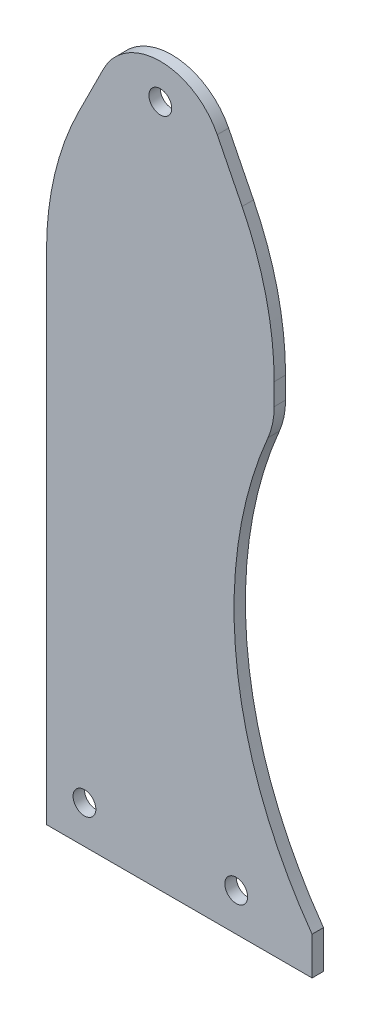
from build123d import *

# Parameters (mm, degrees)
SKETCH_1_R      = 3
EXTRUDE_1_DEPTH = 3


with BuildPart() as part:
    # 草图1 → 凸台-拉伸1 (new body)
    with BuildSketch(Plane.XY):
        with BuildLine():
            Line((8.44582472, 166.89164944), (15, 180))
            ThreePointArc((15, 180), (30, 189.270509831), (45, 180))
            Line((45, 180), (51.55417528, 166.89164944))
            ThreePointArc((51.55417528, 166.89164944), (57.859919157, 149.494795444), (60, 131.1145618))
            Line((60, 131.1145618), (60, 125.412430481))
            ThreePointArc((60, 125.412430481), (59.589066182, 121.379009336), (58.373151387, 117.511335106))
            ThreePointArc((58.373151387, 117.511335106), (50.063143822, 62.228284379), (70, 10))
            Line((70, 10), (70, 0))
            Line((70, 0), (60, 0))
            Line((60, 0), (0, 0))
            Line((0, 0), (0, 10))
            Line((0, 10), (0, 131.1145618))
            ThreePointArc((0, 131.1145618), (2.140080843, 149.494795444), (8.44582472, 166.89164944))
        make_face()
        with Locations((10, 10)):
            Circle(SKETCH_1_R, mode=Mode.SUBTRACT)
        with Locations((50, 10)):
            Circle(SKETCH_1_R, mode=Mode.SUBTRACT)
        with Locations((30, 180)):
            Circle(SKETCH_1_R, mode=Mode.SUBTRACT)
    extrude(amount=EXTRUDE_1_DEPTH)


solid = part.part
